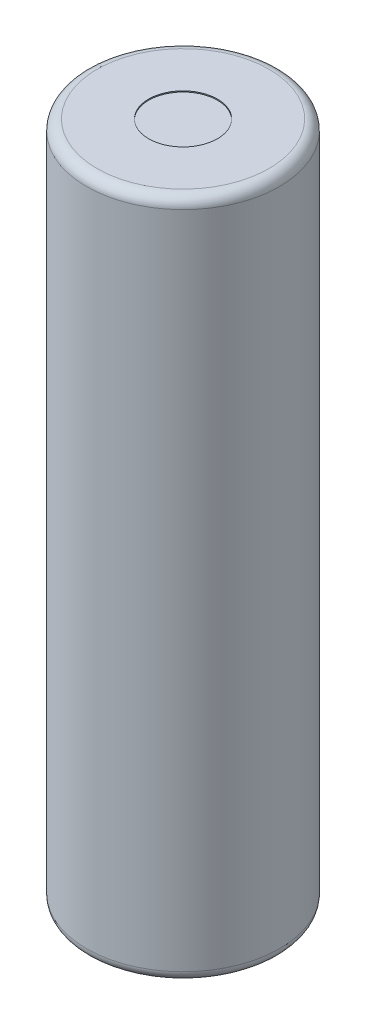
from build123d import *

# Parameters (mm, degrees)
SKETCH2_R           = 9.25
BOSS_EXTRUDE1_DEPTH = 32.65
FILLET1_R           = 1
SKETCH3_R           = 3.3
CUT_EXTRUDE1_DEPTH  = 0.1
SKETCH4_R           = 3.3
BOSS_EXTRUDE2_DEPTH = 0.5
FILLET2_R           = 0.25


with BuildPart() as part:
    # Sketch2 → Boss-Extrude1 (new body, symmetric)
    with BuildSketch(Plane(origin=(0, 0, 0), x_dir=(1, 0, 0), z_dir=(0, 1, 0))):
        Circle(SKETCH2_R)
    extrude(amount=BOSS_EXTRUDE1_DEPTH, both=True)

    # Fillet1
    fillet1_edges = [part.edges().sort_by_distance(p)[0] for p in [
        (-9.25, -32.65, 0),
        (-9.25, 32.65, 0),
    ]]
    fillet(fillet1_edges, radius=FILLET1_R)

    # Sketch3 → Cut-Extrude1 (cut)
    with BuildSketch(Plane(origin=(0, 32.65, 0), x_dir=(1, 0, 0), z_dir=(0, 1, 0))):
        Circle(SKETCH3_R)
    extrude(amount=-CUT_EXTRUDE1_DEPTH, mode=Mode.SUBTRACT)

    # Sketch4 → Boss-Extrude2 (add)
    with BuildSketch(Plane.XZ.offset(32.65)):
        Circle(SKETCH4_R)
    extrude(amount=BOSS_EXTRUDE2_DEPTH)

    # Fillet2
    fillet2_edges = [part.edges().sort_by_distance(p)[0] for p in [
        (-3.3, -33.15, 0),
    ]]
    fillet(fillet2_edges, radius=FILLET2_R)


solid = part.part
